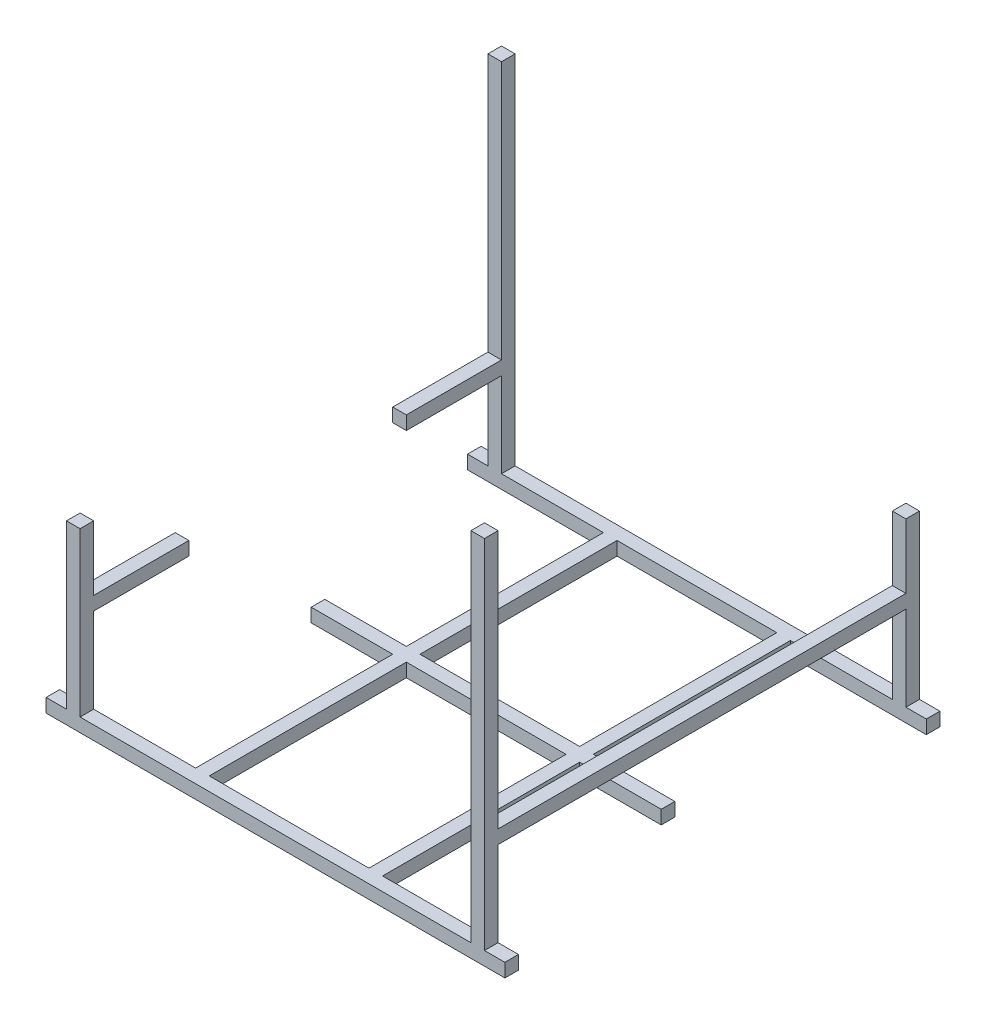
from build123d import *

# Parameters (mm, degrees)
SKETCH_1_W          = 235
SKETCH_1_H          = 600
EXTRUDE_1_DEPTH     = 20
EXTRUDE_4_DEPTH     = 20
SKETCH_6_W          = 640
SKETCH_6_H          = 20
EXTRUDE_6_DEPTH     = 20
SKETCH1_W           = 320
SKETCH1_H           = 20
CUT_EXTRUDE1_DEPTH  = 20
SKETCH2_W           = 515
SKETCH2_H           = 20
EXTRUDE1_DEPTH      = 20
SKETCH3_W           = 20
SKETCH3_H           = 20
BOSS_EXTRUDE1_DEPTH = 285


with BuildPart() as part:
    # 草图1 → 凸台-拉伸1 (new body)
    with BuildSketch(Plane(origin=(0, 0, 0), x_dir=(1, 0, 0), z_dir=(0, 1, 0))):
        Polygon((-221.510078765, -7.502951786), (-21.510078765, -7.502951786), (-21.510078765, 592.497048214), (-221.510078765, 592.497048214), (-221.510078765, 612.497048214), (453.489921235, 612.497048214), (453.489921235, 592.497048214), (253.489921235, 592.497048214), (253.489921235, -7.502951786), (453.489921235, -7.502951786), (453.489921235, -27.502951786), (-221.510078765, -27.502951786), align=None)
        with Locations((115.989921235, 292.497048214)):
            Rectangle(SKETCH_1_W, SKETCH_1_H, mode=Mode.SUBTRACT)
    extrude(amount=EXTRUDE_1_DEPTH)

    # 草图2 → 凸台-拉伸4 (add)
    with BuildSketch(Plane.ZY.offset(191.510078765)):
        Polygon((27.502951786, 20), (7.502951786, 20), (7.502951786, 165), (7.502951786, 260), (27.502951786, 260), align=None)
        Polygon((-592.497048214, 260), (-592.497048214, 165), (-592.497048214, 20), (-612.497048214, 20), (-612.497048214, 260), align=None)
    extrude_4 = extrude(amount=-EXTRUDE_4_DEPTH)

    # 镜向3: 凸台-拉伸4 across plane
    add(extrude_4.mirror(Plane(origin=(115.989921235, 0, 0), x_dir=(0, 0, 1), z_dir=(1, 0, 0))))

    # 草图6 → 凸台-拉伸6 (add)
    with BuildSketch(Plane.ZY.offset(191.510078765)):
        with Locations((-292.497048214, 155)):
            Rectangle(SKETCH_6_W, SKETCH_6_H)
    extrude_6 = extrude(amount=-EXTRUDE_6_DEPTH)

    # 镜向6: 凸台-拉伸6 across plane
    add(extrude_6.mirror(Plane(origin=(115.989921235, 0, 0), x_dir=(0, 0, 1), z_dir=(1, 0, 0))))

    # Sketch1 → Cut-Extrude1 (cut)
    with BuildSketch(Plane.ZY.offset(191.510078765)):
        with Locations((-292.497048214, 155)):
            Rectangle(SKETCH1_W, SKETCH1_H)
    extrude(amount=-CUT_EXTRUDE1_DEPTH, mode=Mode.SUBTRACT)

    # Sketch2 → Extrude1 (add)
    with BuildSketch(Plane(origin=(0, 0, 0), x_dir=(-1, 0, 0), z_dir=(0, -1, 0))):
        with Locations((-115.989921235, 292.497048214)):
            Rectangle(SKETCH2_W, SKETCH2_H)
    extrude(amount=-EXTRUDE1_DEPTH)

    # Sketch3 → Boss-Extrude1 (add)
    with BuildSketch(Plane(origin=(0, 260, 0), x_dir=(1, 0, 0), z_dir=(0, 1, 0))):
        with Locations((-181.510078765, 602.497048214)):
            Rectangle(SKETCH3_W, SKETCH3_H)
        with Locations((413.489921235, -17.502951786)):
            Rectangle(SKETCH3_W, SKETCH3_H)
    extrude(amount=BOSS_EXTRUDE1_DEPTH)


solid = part.part
